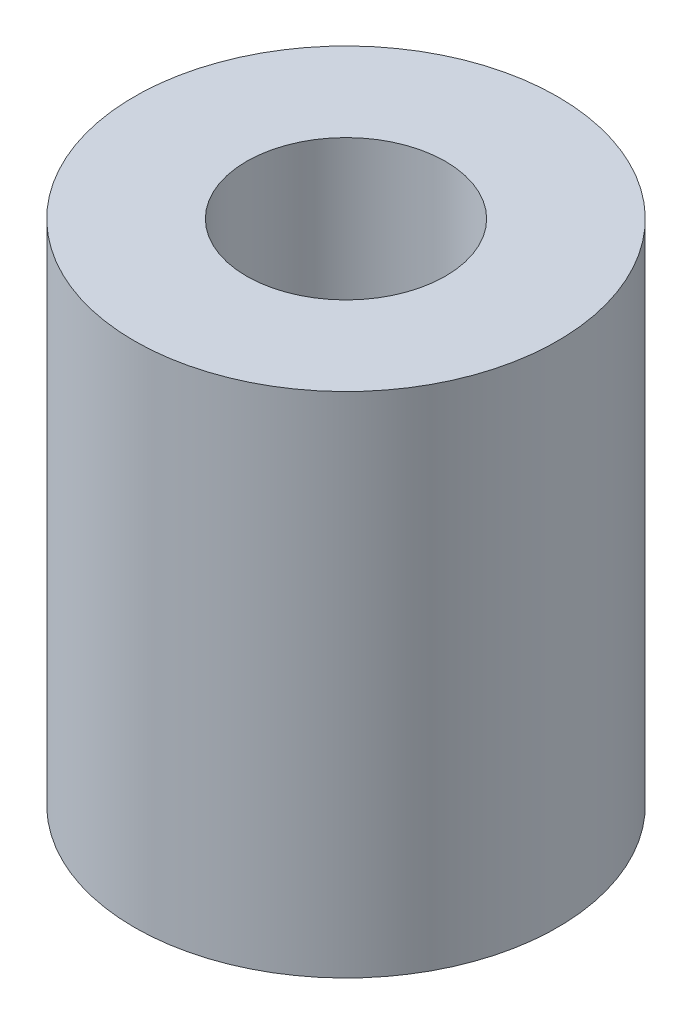
from build123d import *

# Parameters (mm, degrees)
SKETCH1_R           = 5
SKETCH1_R_2         = 2.35
BOSS_EXTRUDE1_DEPTH = 12
SKETCH2_R           = 2.35
CUT_EXTRUDE1_DEPTH  = 9


with BuildPart() as part:
    # Sketch1 → Boss-Extrude1 (new body)
    with BuildSketch(Plane(origin=(0, 0, 0), x_dir=(1, 0, 0), z_dir=(0, 1, 0))):
        Circle(SKETCH1_R)
        Circle(SKETCH1_R_2, mode=Mode.SUBTRACT)
        Circle(SKETCH1_R_2)
    extrude(amount=BOSS_EXTRUDE1_DEPTH)

    # Sketch2 → Cut-Extrude1 (cut)
    with BuildSketch(Plane(origin=(0, 12, 0), x_dir=(1, 0, 0), z_dir=(0, 1, 0))):
        Circle(SKETCH2_R)
    extrude(amount=-CUT_EXTRUDE1_DEPTH, mode=Mode.SUBTRACT)


solid = part.part
